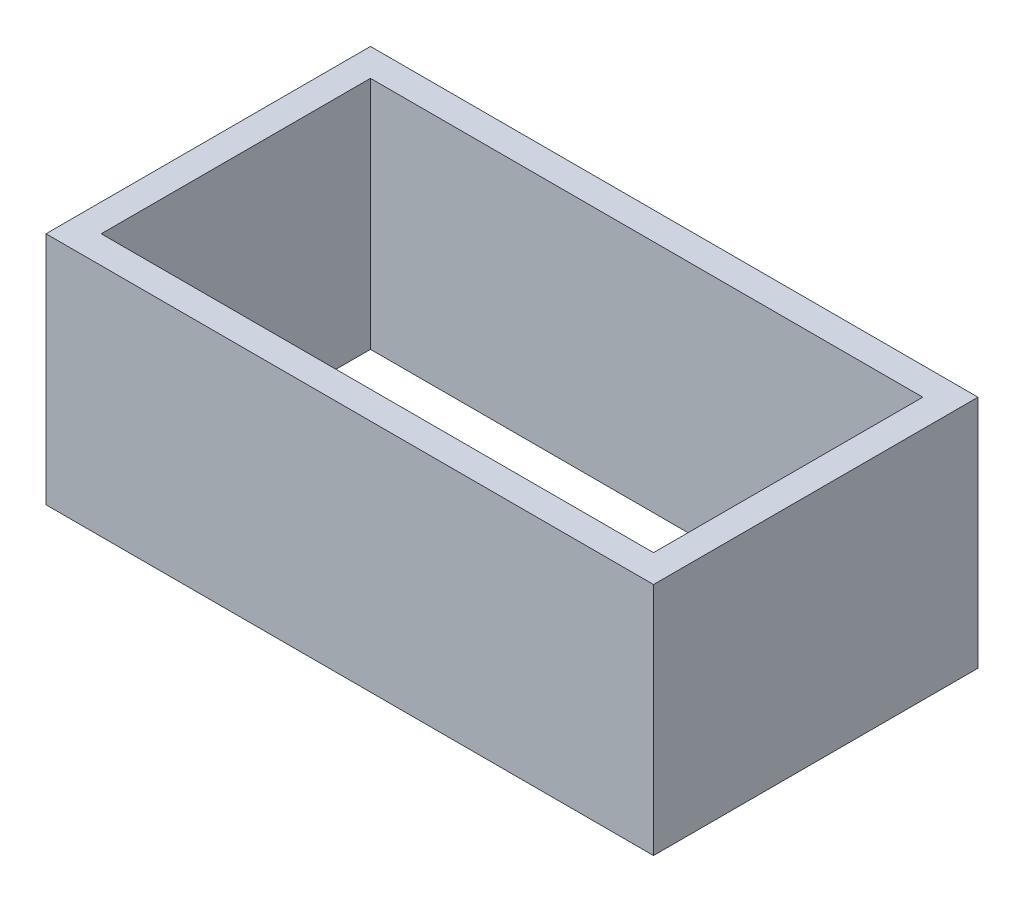
from build123d import *

# Parameters (mm, degrees)
SKETCH1_W           = 44
SKETCH1_H           = 23.5
SKETCH1_W_2         = 40
SKETCH1_H_2         = 19.5
BOSS_EXTRUDE1_DEPTH = 17


with BuildPart() as part:
    # Sketch1 → Boss-Extrude1 (new body)
    with BuildSketch(Plane(origin=(0, 0, 0), x_dir=(1, 0, 0), z_dir=(0, 1, 0))):
        Rectangle(SKETCH1_W, SKETCH1_H)
        Rectangle(SKETCH1_W_2, SKETCH1_H_2, mode=Mode.SUBTRACT)
    extrude(amount=BOSS_EXTRUDE1_DEPTH)


solid = part.part
